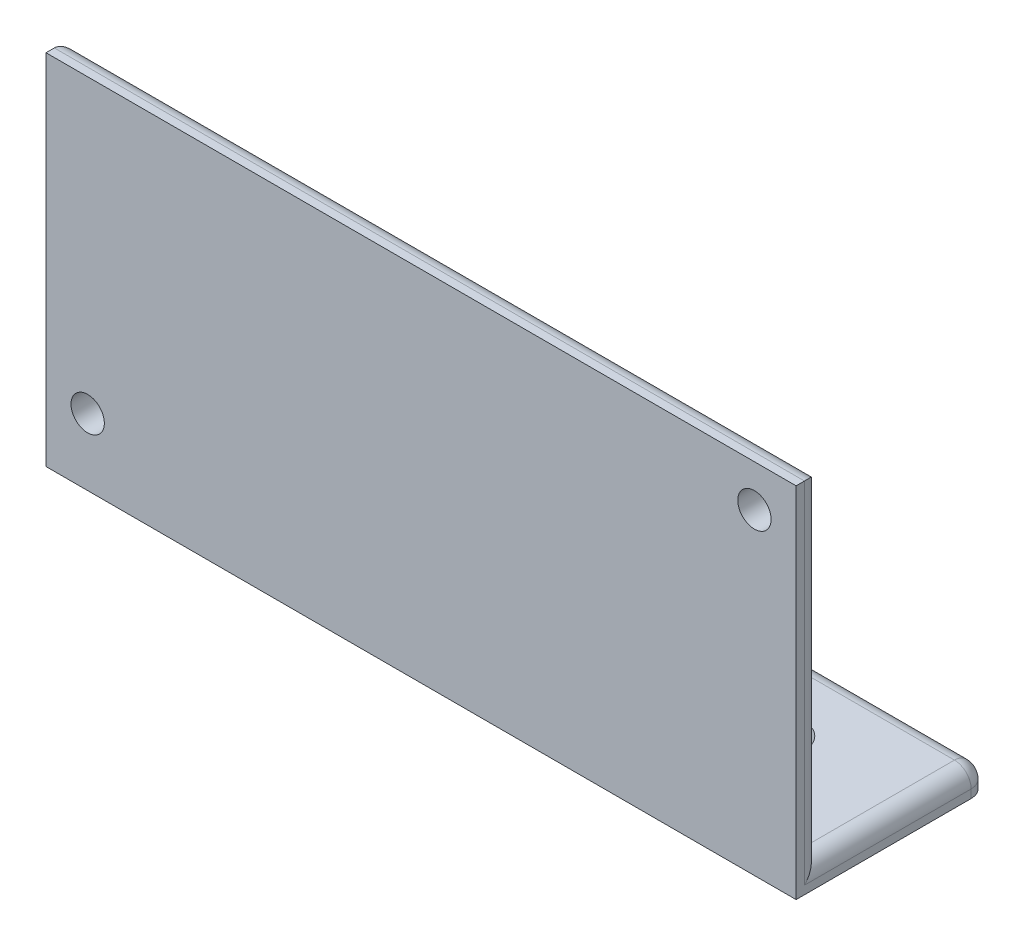
from build123d import *

# Parameters (mm, degrees)
SKETCH1_W           = 45
SKETCH1_H           = 20
SKETCH1_R           = 1
BOSS_EXTRUDE1_DEPTH = 1.5
SKETCH2_W           = 45
SKETCH2_H           = 11.5
SKETCH2_R           = 1.5
BOSS_EXTRUDE2_DEPTH = 1.5
FILLET1_R           = 1


with BuildPart() as part:
    # Sketch1 → Boss-Extrude1 (new body)
    with BuildSketch(Plane.XY):
        Rectangle(SKETCH1_W, SKETCH1_H)
        with Locations((20, 7.5)):
            Circle(SKETCH1_R, mode=Mode.SUBTRACT)
        with Locations((-20, -7.5)):
            Circle(SKETCH1_R, mode=Mode.SUBTRACT)
    extrude(amount=BOSS_EXTRUDE1_DEPTH)

    # Sketch2 → Boss-Extrude2 (add)
    with BuildSketch(Plane.XZ.offset(10)):
        with Locations((0, -4.25)):
            Rectangle(SKETCH2_W, SKETCH2_H)
        with Locations((-15, -5)):
            Circle(SKETCH2_R, mode=Mode.SUBTRACT)
        with Locations((15, -5)):
            Circle(SKETCH2_R, mode=Mode.SUBTRACT)
    extrude(amount=BOSS_EXTRUDE2_DEPTH)

    # Fillet1
    fillet1_edges = [part.edges().sort_by_distance(p)[0] for p in [
        (22.5, -10, -5),
        (22.5, -10.75, -10),
        (-22.5, -10, -5),
        (0, -10, -10),
        (-22.5, -10.75, -10),
        (0, 10, 0),
        (22.5, 0, 0),
        (-22.5, 0, 0),
    ]]
    fillet(fillet1_edges, radius=FILLET1_R)


solid = part.part
